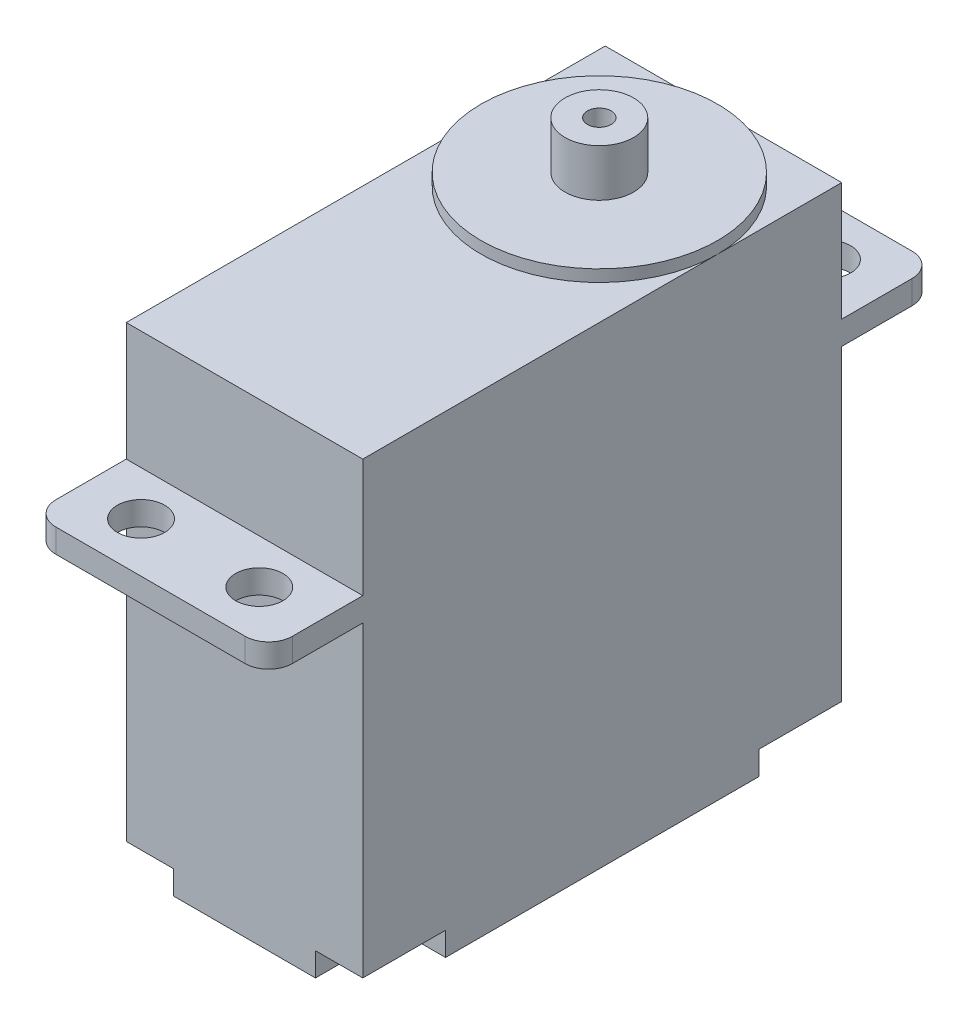
from build123d import *

# Parameters (mm, degrees)
SKETCH2_W           = 20
SKETCH2_H           = 40.5
BOSS_EXTRUDE1_DEPTH = 28
SKETCH3_W           = 20
SKETCH3_H           = 56.4
BOSS_EXTRUDE2_DEPTH = 2
SKETCH4_W           = 20
SKETCH4_H           = 40.5
BOSS_EXTRUDE3_DEPTH = 10
SKETCH5_R           = 10
BOSS_EXTRUDE4_DEPTH = 1
SKETCH6_R           = 2.9
SKETCH6_R_2         = 1
BOSS_EXTRUDE5_DEPTH = 4
SKETCH7_R           = 2
CUT_EXTRUDE1_DEPTH  = 2
FILLET1_R           = 2
SKETCH8_W           = 4
SKETCH8_H           = 7
CUT_EXTRUDE2_DEPTH  = 2
SKETCH9_W           = 8
SKETCH9_H           = 3
BOSS_EXTRUDE6_DEPTH = 5


with BuildPart() as part:
    # Sketch2 → Boss-Extrude1 (new body)
    with BuildSketch(Plane(origin=(0, 77, 0), x_dir=(1, 0, 0), z_dir=(0, 1, 0))):
        with Locations((-39.282617367, 276.14521975)):
            Rectangle(SKETCH2_W, SKETCH2_H)
    extrude(amount=BOSS_EXTRUDE1_DEPTH)

    # Sketch3 → Boss-Extrude2 (add)
    with BuildSketch(Plane(origin=(0, 105, 0), x_dir=(1, 0, 0), z_dir=(0, 1, 0))):
        with Locations((-39.282617367, 276.14521975)):
            Rectangle(SKETCH3_W, SKETCH3_H)
    extrude(amount=BOSS_EXTRUDE2_DEPTH)

    # Sketch4 → Boss-Extrude3 (add)
    with BuildSketch(Plane(origin=(0, 107, 0), x_dir=(1, 0, 0), z_dir=(0, 1, 0))):
        with Locations((-39.282617367, 276.14521975)):
            Rectangle(SKETCH4_W, SKETCH4_H)
    extrude(amount=BOSS_EXTRUDE3_DEPTH)

    # Sketch5 → Boss-Extrude4 (add)
    with BuildSketch(Plane(origin=(0, 117, 0), x_dir=(1, 0, 0), z_dir=(0, 1, 0))):
        with Locations((-39.282617367, 285.89521975)):
            Circle(SKETCH5_R)
    extrude(amount=BOSS_EXTRUDE4_DEPTH)

    # Sketch6 → Boss-Extrude5 (add)
    with BuildSketch(Plane(origin=(0, 118, 0), x_dir=(1, 0, 0), z_dir=(0, 1, 0))):
        with Locations((-39.282617367, 285.89521975)):
            Circle(SKETCH6_R)
        with Locations((-39.282617367, 285.89521975)):
            Circle(SKETCH6_R_2, mode=Mode.SUBTRACT)
    extrude(amount=BOSS_EXTRUDE5_DEPTH)

    # Sketch7 → Cut-Extrude1 (cut)
    with BuildSketch(Plane(origin=(0, 107, 0), x_dir=(1, 0, 0), z_dir=(0, 1, 0))):
        with Locations((-44.282617367, 252.14521975)):
            Circle(SKETCH7_R)
        with Locations((-34.282617367, 252.14521975)):
            Circle(SKETCH7_R)
        with Locations((-34.282617367, 300.14521975)):
            Circle(SKETCH7_R)
        with Locations((-44.282617367, 300.14521975)):
            Circle(SKETCH7_R)
    extrude(amount=-CUT_EXTRUDE1_DEPTH, mode=Mode.SUBTRACT)

    # Fillet1
    fillet1_edges = [part.edges().sort_by_distance(p)[0] for p in [
        (-49.282617367, 106, -247.94521975),
        (-29.282617367, 106, -247.94521975),
        (-49.282617367, 106, -304.34521975),
        (-29.282617367, 106, -304.34521975),
    ]]
    fillet(fillet1_edges, radius=FILLET1_R)

    # Sketch8 → Cut-Extrude2 (cut)
    with BuildSketch(Plane.XZ.offset(-77)):
        with Locations((-31.282617367, -259.39521975)):
            Rectangle(SKETCH8_W, SKETCH8_H)
        with Locations((-31.282617367, -292.89521975)):
            Rectangle(SKETCH8_W, SKETCH8_H)
        with Locations((-47.282617367, -292.89521975)):
            Rectangle(SKETCH8_W, SKETCH8_H)
        with Locations((-47.282617367, -259.39521975)):
            Rectangle(SKETCH8_W, SKETCH8_H)
    extrude(amount=-CUT_EXTRUDE2_DEPTH, mode=Mode.SUBTRACT)

    # Sketch9 → Boss-Extrude6 (add)
    with BuildSketch(Plane(origin=(0, 0, -296.39521975), x_dir=(-1, 0, 0), z_dir=(0, 0, -1))):
        with Locations((39.282617367, 78.5)):
            Rectangle(SKETCH9_W, SKETCH9_H)
    extrude(amount=BOSS_EXTRUDE6_DEPTH)


solid = part.part
